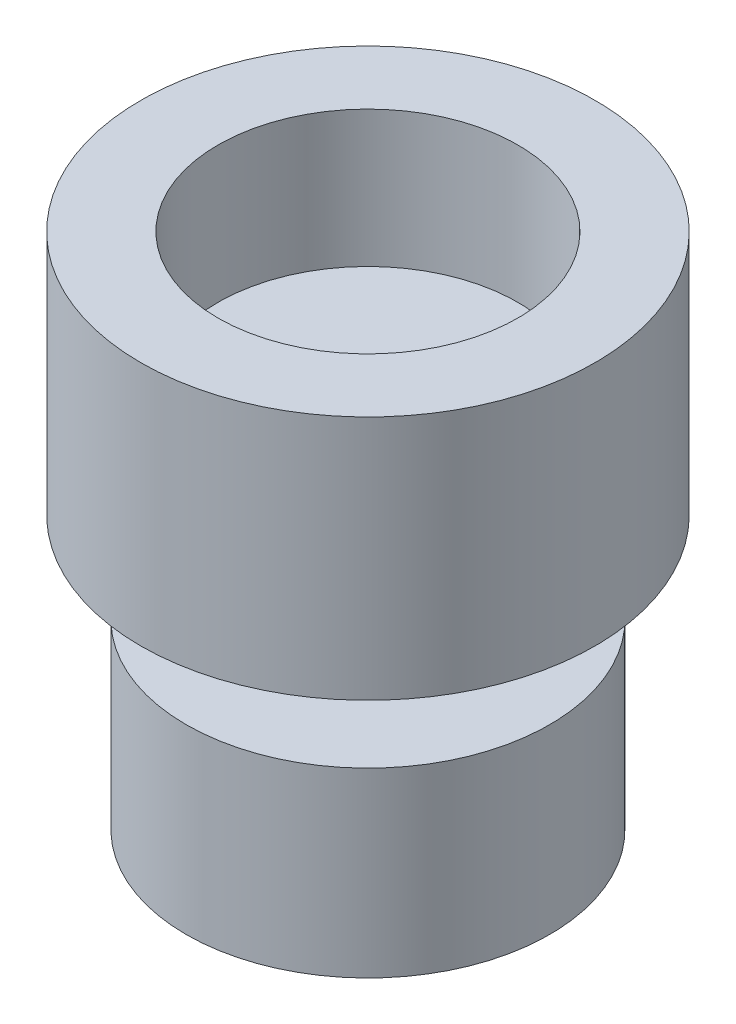
from build123d import *

# Parameters (mm, degrees)
SKETCH1_R           = 2.5
BOSS_EXTRUDE1_DEPTH = 2.7
SKETCH1_3_R         = 2
BOSS_EXTRUDE2_DEPTH = 1
SKETCH5_R           = 1
BOSS_EXTRUDE3_DEPTH = 1
SKETCH6_R           = 2
BOSS_EXTRUDE4_DEPTH = 2
SKETCH12_R          = 1.65
CUT_EXTRUDE1_DEPTH  = 1.5


with BuildPart() as part:
    # Sketch1 → Boss-Extrude1 (new body)
    with BuildSketch(Plane(origin=(0, 0, 0), x_dir=(1, 0, 0), z_dir=(0, 1, 0))):
        with Locations((-0.522013312, 0.511138034)):
            Circle(SKETCH1_R)
    extrude(amount=BOSS_EXTRUDE1_DEPTH)

    # Sketch1_3 → Boss-Extrude2 (add)
    with BuildSketch(Plane(origin=(0, 0, 0), x_dir=(1, 0, 0), z_dir=(0, 1, 0))):
        with Locations((-0.522013312, 0.511138034)):
            Circle(SKETCH1_3_R)
    extrude(amount=BOSS_EXTRUDE2_DEPTH)

    # Sketch5 → Boss-Extrude3 (add)
    with BuildSketch(Plane.XZ):
        with Locations((-0.522013312, -0.511138034)):
            Circle(SKETCH5_R)
    extrude(amount=BOSS_EXTRUDE3_DEPTH)

    # Sketch6 → Boss-Extrude4 (add)
    with BuildSketch(Plane.XZ.offset(1)):
        with Locations((-0.522013312, -0.511138034)):
            Circle(SKETCH6_R)
    extrude(amount=BOSS_EXTRUDE4_DEPTH)

    # Sketch12 → Cut-Extrude1 (cut)
    with BuildSketch(Plane(origin=(0, 2.7, 0), x_dir=(1, 0, 0), z_dir=(0, 1, 0))):
        with Locations((-0.522013312, 0.511138034)):
            Circle(SKETCH12_R)
    extrude(amount=-CUT_EXTRUDE1_DEPTH, mode=Mode.SUBTRACT)


solid = part.part
